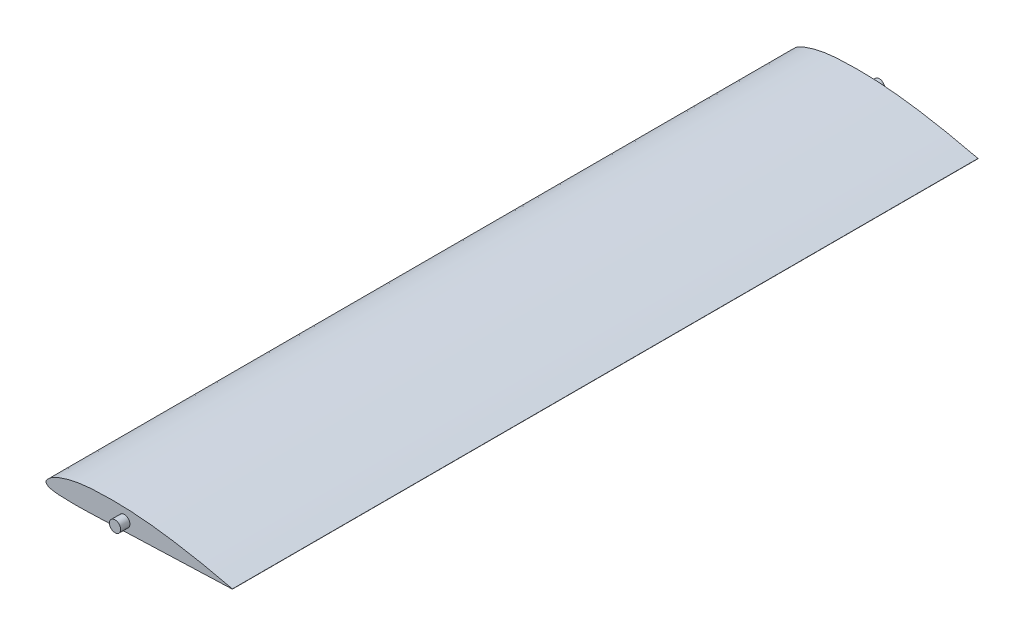
from build123d import *

# Parameters (mm, degrees)
BOSS_EXTRUDE4_DEPTH = 200
BOSS_EXTRUDE5_START = 200
SKETCH8_R           = 3
BOSS_EXTRUDE5_DEPTH = 5


with BuildPart() as part:
    # Sketch7 → Boss-Extrude4 (new body, symmetric)
    with BuildSketch(Plane.XY):
        with BuildLine():
            Line((100, 0.059926239), (100, -0.059926239))
            add(Edge.make_bspline(
                [(100, 0.059926239), (99.666693747, 0.138937278), (99.000120089, 0.296950147), (98.000251553, 0.533477245), (97.000374754, 0.768863582), (95.667563882, 1.080423834), (94.001571327, 1.463921037), (92.001607392, 1.912928369), (90.001661959, 2.35152967), (88.001782961, 2.78020774), (86.001922334, 3.198740247), (83.336833756, 3.742446912), (79.341246618, 4.52504218), (75.339253815, 5.251480629), (72.002725374, 5.817455091), (69.337494052, 6.253633834), (66.67113132, 6.666085487), (64.003319887, 7.05020382), (62.003458627, 7.322700435), (59.338348507, 7.663839853), (56.671635808, 7.969625684), (54.00374799, 8.239513822), (52.003798273, 8.423867645), (50.003848632, 8.590130705), (48.003933302, 8.738357475), (46.004010131, 8.867191768), (44.004059333, 8.974938324), (42.00408216, 9.06001958), (40.004073157, 9.120896449), (38.004028257, 9.155636941), (36.004010842, 9.16581868), (34.004028677, 9.153597138), (32.004075219, 9.121079057), (30.004147102, 9.070048944), (28.004054642, 9.003501567), (26.003749691, 8.913395813), (24.003198316, 8.789654407), (22.002329662, 8.622438457), (20.001074539, 8.401778087), (18.000119897, 8.11642817), (15.999442234, 7.765908335), (13.99821196, 7.352634316), (11.995741465, 6.872449576), (9.992304312, 6.311647305), (7.989163651, 5.653058953), (6.321829328, 5.023992338), (4.992999833, 4.432160705), (3.985953941, 3.916642222), (2.969911706, 3.304009047), (2.03188359, 2.589254179), (1.327379489, 1.910996083), (0.789670594, 1.365786536), (0.448168069, 0.967197603), (0.223663802, 0.624140906), (0.113778156, 0.399455595), (0.043632386, 0.205862057), (-0.019888352, -0.073858969), (0.012405126, -0.364936741), (0.113724473, -0.61829604), (0.222486641, -0.819796167), (0.443568241, -1.113448644), (0.780453339, -1.424800094), (1.306048629, -1.780523967), (2.051832708, -2.068697642), (3.00325105, -2.260246769), (4.002455459, -2.459046986), (5.003116609, -2.611772939), (6.336539162, -2.753035401), (8.004927219, -2.849133475), (10.004957249, -2.943900683), (12.00521234, -3.001163327), (14.005302457, -3.028252285), (16.005329278, -3.028922732), (18.005280022, -3.00767532), (20.005177795, -2.968632871), (22.005047307, -2.916015127), (24.671655096, -2.831835004), (27.338001875, -2.732599294), (30.004370014, -2.630358195), (32.670844272, -2.530253629), (35.337367942, -2.432664914), (38.003891325, -2.335916653), (40.003772178, -2.263336253), (42.003646598, -2.190344822), (44.003518246, -2.116978304), (46.670017485, -2.018905686), (50.003131257, -1.895985195), (53.336259012, -1.773487723), (56.002761129, -1.675613658), (58.002635623, -1.602215299), (60.669136614, -1.504383964), (63.33563494, -1.406463335), (66.002134289, -1.30854392), (68.002008016, -1.235067996), (70.001882854, -1.161619013), (72.001757026, -1.088158518), (79.33463079, -0.81887358), (86.667503341, -0.549558953), (94.333688948, -0.268022583), (96.333563231, -0.194575108), (98.33343832, -0.121146278), (99.333375156, -0.084410903), (100, -0.059926239)],
                knots=[0, 0, 0, 0, 0.005027801, 0.010055017, 0.015080974, 0.020105044, 0.030145218, 0.040173571, 0.050190814, 0.060197659, 0.070194195, 0.080180308, 0.10012104, 0.129954283, 0.13987867, 0.149793455, 0.169594378, 0.179479765, 0.189354685, 0.199219007, 0.218916578, 0.228751143, 0.238577241, 0.248395624, 0.258207006, 0.268011825, 0.277810572, 0.287603995, 0.297393107, 0.307179233, 0.316963997, 0.326748798, 0.336534696, 0.346322446, 0.356112709, 0.36590763, 0.375711448, 0.385530843, 0.395375733, 0.40525931, 0.415192466, 0.425184001, 0.435248266, 0.445412162, 0.455710796, 0.466190924, 0.471552117, 0.477054429, 0.482786856, 0.488945965, 0.494315962, 0.497126381, 0.500187407, 0.502001032, 0.503128101, 0.503849916, 0.505020082, 0.50731785, 0.507986412, 0.509023655, 0.510668013, 0.513358344, 0.515715835, 0.519949409, 0.524973134, 0.529954393, 0.534903202, 0.539824097, 0.549630395, 0.559425349, 0.569214158, 0.578999725, 0.588784356, 0.598569501, 0.608355927, 0.618143876, 0.627933302, 0.647515398, 0.65730712, 0.667098651, 0.686681109, 0.696472189, 0.706263271, 0.716054413, 0.725845618, 0.73563686, 0.755219388, 0.774801864, 0.784593083, 0.794384298, 0.804175512, 0.823757953, 0.833549178, 0.843340406, 0.853131632, 0.862922858, 0.872714083, 0.960835102, 0.970626327, 0.985313162, 0.990208774, 1, 1, 1, 1], degree=3))
        make_face()
    extrude(amount=BOSS_EXTRUDE4_DEPTH, both=True)

    # Sketch8 → Boss-Extrude5 (add)
    with BuildSketch(Plane.XY.offset(BOSS_EXTRUDE5_START)):
        with Locations((42.036918006, 2.669166157)):
            Circle(SKETCH8_R)
    boss_extrude5 = extrude(amount=BOSS_EXTRUDE5_DEPTH)

    # Mirror1: Boss-Extrude5 across plane
    add(boss_extrude5.mirror(Plane.XY))


solid = part.part
